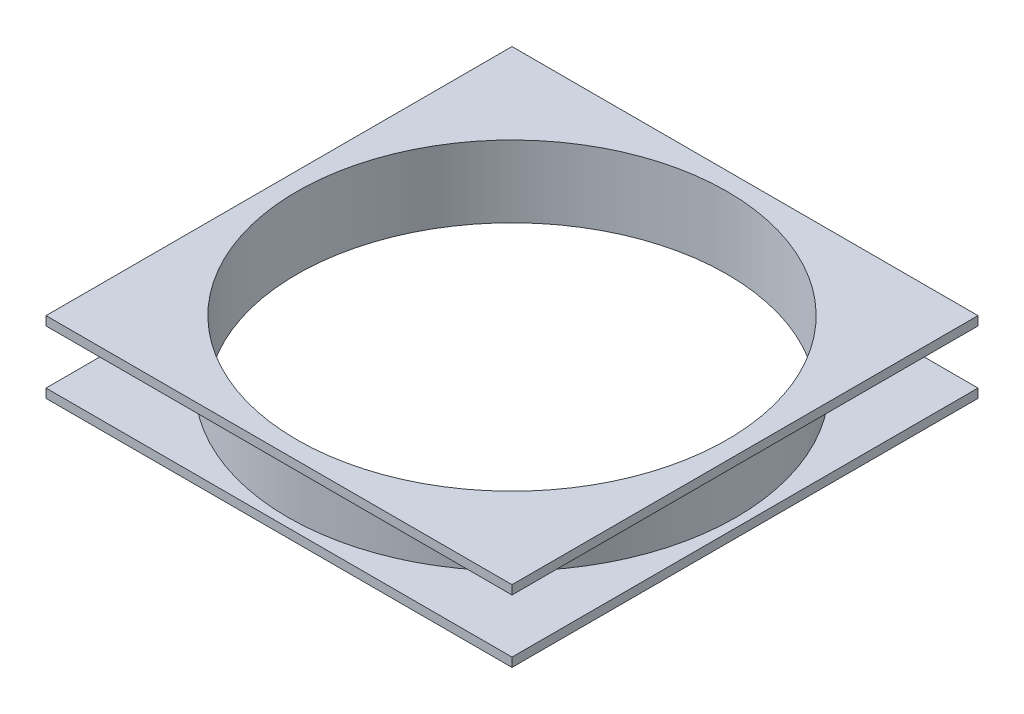
from build123d import *

# Parameters (mm, degrees)
SKETCH1_R           = 62.5
SKETCH1_R_2         = 60
BOSS_EXTRUDE1_DEPTH = 7.5
SKETCH3_W           = 130
SKETCH3_H           = 130
SKETCH3_R           = 60
BOSS_EXTRUDE2_DEPTH = 2.5
SKETCH4_W           = 130
SKETCH4_H           = 130
SKETCH4_R           = 60
BOSS_EXTRUDE3_DEPTH = 2.5


with BuildPart() as part:
    # Sketch1 → Boss-Extrude1 (new body, symmetric)
    with BuildSketch(Plane(origin=(0, 0, 0), x_dir=(1, 0, 0), z_dir=(0, 1, 0))):
        Circle(SKETCH1_R)
        Circle(SKETCH1_R_2, mode=Mode.SUBTRACT)
    extrude(amount=BOSS_EXTRUDE1_DEPTH, both=True)

    # Sketch3 → Boss-Extrude2 (add)
    with BuildSketch(Plane(origin=(0, 7.5, 0), x_dir=(1, 0, 0), z_dir=(0, 1, 0))):
        Rectangle(SKETCH3_W, SKETCH3_H)
        Circle(SKETCH3_R, mode=Mode.SUBTRACT)
    extrude(amount=BOSS_EXTRUDE2_DEPTH)

    # Sketch4 → Boss-Extrude3 (add)
    with BuildSketch(Plane.XZ.offset(7.5)):
        Rectangle(SKETCH4_W, SKETCH4_H)
        Circle(SKETCH4_R, mode=Mode.SUBTRACT)
    extrude(amount=BOSS_EXTRUDE3_DEPTH)


solid = part.part
